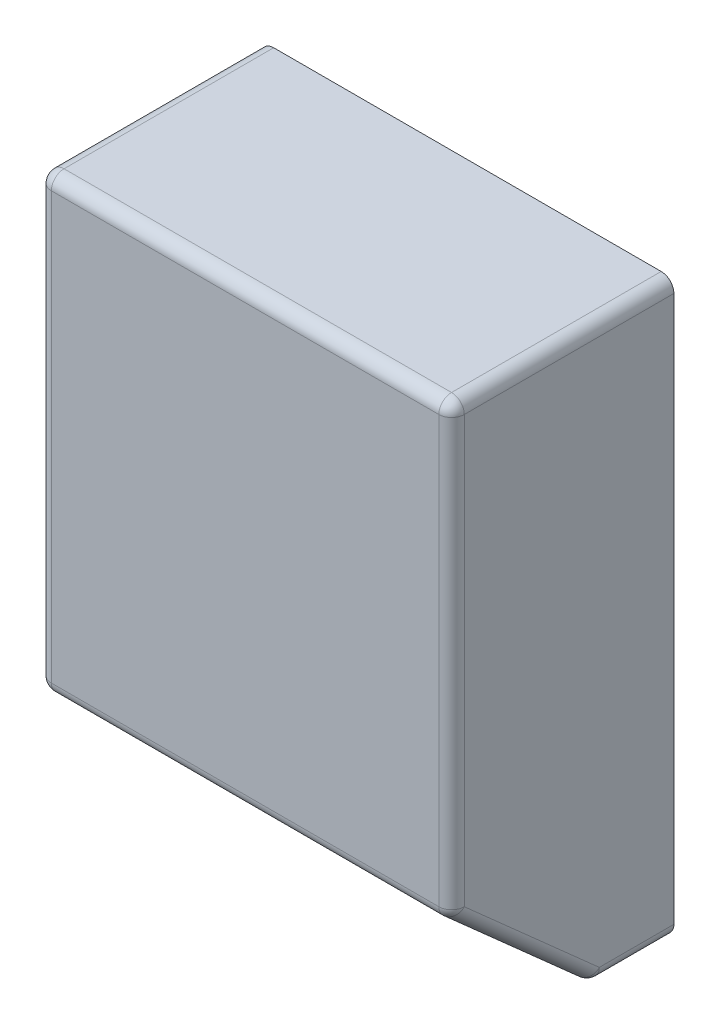
from build123d import *

# Parameters (mm, degrees)
SKETCH1_W           = 130
SKETCH1_H           = 180
BOSS_EXTRUDE1_DEPTH = 70
CUT_EXTRUDE1_DEPTH  = 131
FILLET2_R           = 4
SHELL1_T            = -2.5
SKETCH3_R           = 8
SKETCH3_W           = 60
SKETCH3_H           = 45
CUT_EXTRUDE2_DEPTH  = 10
CUT_EXTRUDE3_START  = -2.5
SKETCH4_W           = 69.3
SKETCH4_H           = 50
CUT_EXTRUDE3_DEPTH  = 1


with BuildPart() as part:
    # Sketch1 → Boss-Extrude1 (new body)
    with BuildSketch(Plane.XY):
        Rectangle(SKETCH1_W, SKETCH1_H)
    extrude(amount=BOSS_EXTRUDE1_DEPTH)

    # Sketch2 → Cut-Extrude1 (cut, through all)
    with BuildSketch(Plane.ZY.offset(65)):
        Polygon((70, -50), (25, -90), (70, -90), align=None)
    extrude(amount=-CUT_EXTRUDE1_DEPTH, mode=Mode.SUBTRACT)

    # Fillet2
    fillet2_edges = [part.edges().sort_by_distance(p)[0] for p in [
        (-65, 20, 70),
        (65, -90, 12.5),
        (-65, -90, 12.5),
        (0, -50, 70),
        (65, -70, 47.5),
        (0, -90, 25),
        (-65, -70, 47.5),
        (0, 90, 70),
        (65, 20, 70),
        (-65, 90, 35),
        (65, 90, 35),
    ]]
    fillet(fillet2_edges, radius=FILLET2_R)

    # Shell1
    shell1_openings = [part.faces().sort_by_distance(p)[0] for p in [
        (0, 0, 0),
    ]]
    offset(amount=SHELL1_T, openings=shell1_openings, kind=Kind.INTERSECTION)

    # Sketch3 → Cut-Extrude2 (cut)
    with BuildSketch(Plane(origin=(0, -62.689655172, 55.724137931), x_dir=(1, 0, 0), z_dir=(0, -0.747409319, 0.664363839))):
        with Locations((40.000108275, -9.586715238)):
            Circle(SKETCH3_R)
        with Locations((-11.005976929, -9.586715238)):
            Rectangle(SKETCH3_W, SKETCH3_H)
    extrude(amount=-CUT_EXTRUDE2_DEPTH, mode=Mode.SUBTRACT)

    # Sketch4 → Cut-Extrude3 (cut)
    with BuildSketch(Plane(origin=(0, -62.689655172, 55.724137931), x_dir=(1, 0, 0), z_dir=(0, -0.747409319, 0.664363839)).offset(CUT_EXTRUDE3_START)):
        with Locations((-8.85597671, -9.586715238)):
            Rectangle(SKETCH4_W, SKETCH4_H)
    extrude(amount=CUT_EXTRUDE3_DEPTH, mode=Mode.SUBTRACT)


solid = part.part
